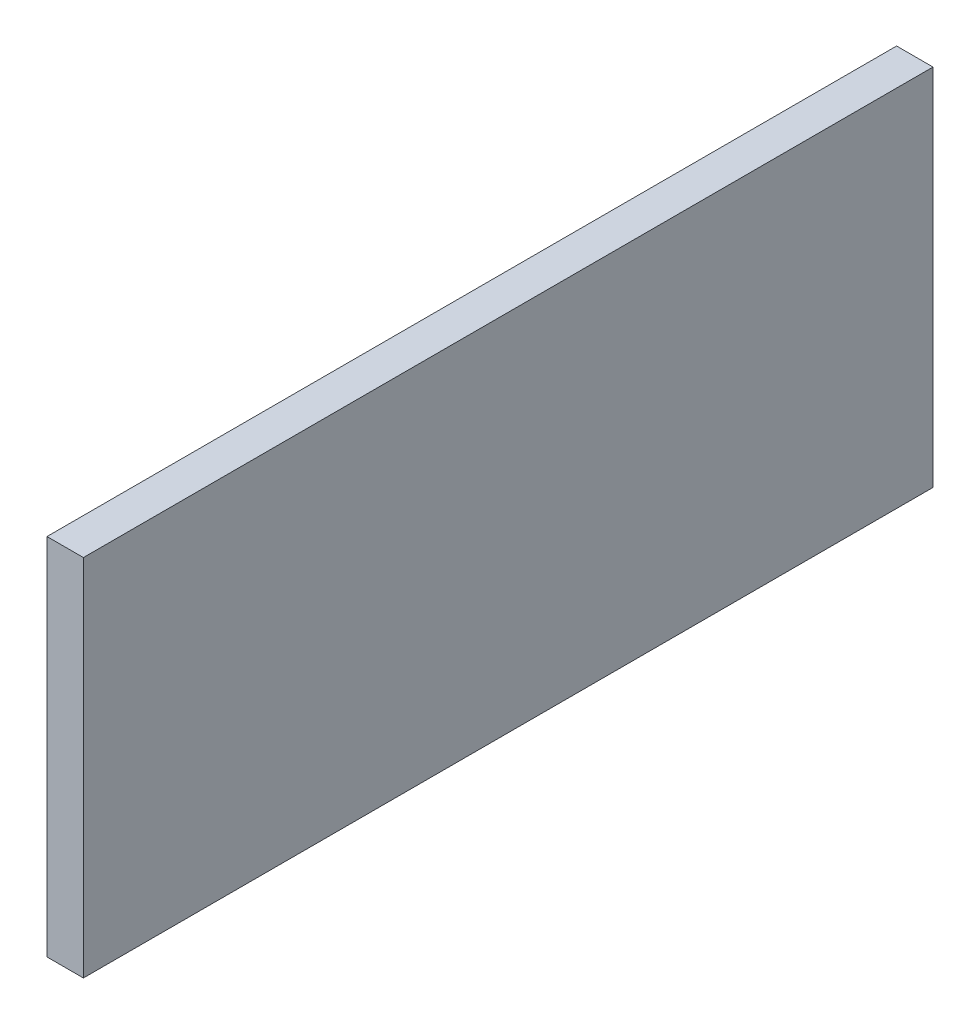
from build123d import *

# Parameters (mm, degrees)
SKETCH1_W           = 70
SKETCH1_H           = 30
BOSS_EXTRUDE1_DEPTH = 3


with BuildPart() as part:
    # Sketch1 → Boss-Extrude1 (new body)
    with BuildSketch(Plane(origin=(0, 0, 0), x_dir=(0, 0, -1), z_dir=(1, 0, 0))):
        Rectangle(SKETCH1_W, SKETCH1_H)
    extrude(amount=BOSS_EXTRUDE1_DEPTH)


solid = part.part
